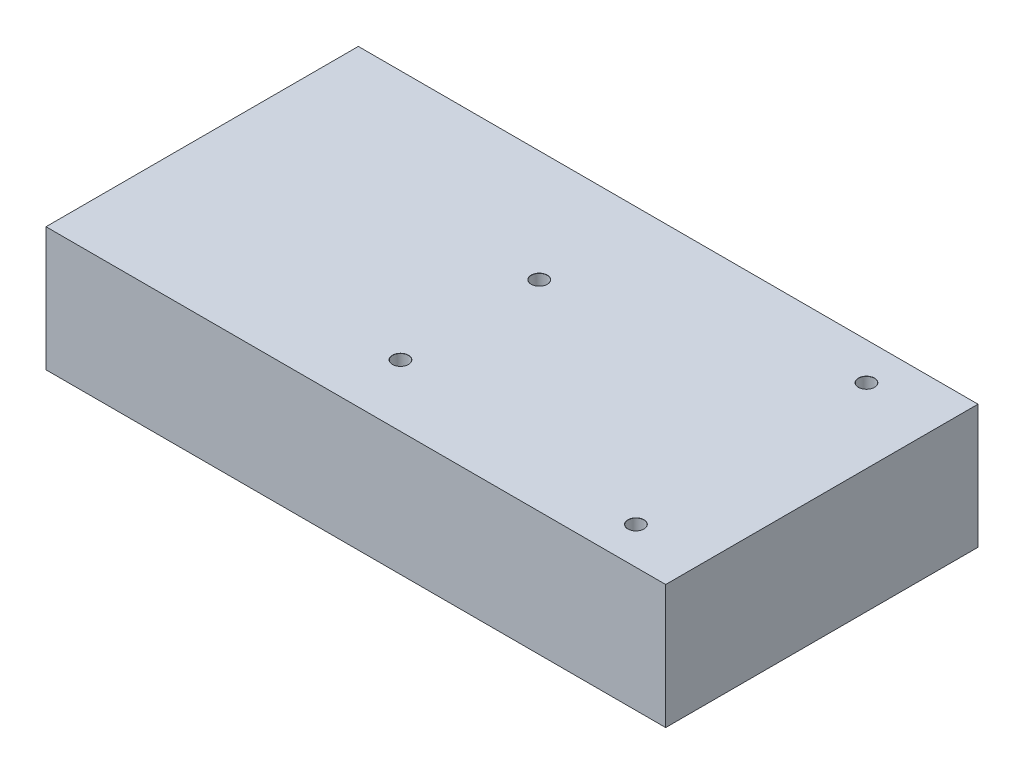
from build123d import *

# Parameters (mm, degrees)
SKETCH1_W                      = 125
SKETCH1_H                      = 63
BOSS_EXTRUDE1_DEPTH            = 25
M3_CLEARANCE_HOLE1_D           = 3.2
M3_CLEARANCE_HOLE1_CSINK_D     = 3.25
M3_CLEARANCE_HOLE1_CSINK_ANGLE = 90


with BuildPart() as part:
    # Sketch1 → Boss-Extrude1 (new body)
    with BuildSketch(Plane(origin=(0, 0, 0), x_dir=(1, 0, 0), z_dir=(0, 1, 0))):
        Rectangle(SKETCH1_W, SKETCH1_H)
    extrude(amount=BOSS_EXTRUDE1_DEPTH)

    # M3 Clearance Hole1 (through all)
    with Locations(Plane(origin=(0, 25, 0), x_dir=(1, 0, 0), z_dir=(0, 1, 0))):
        with Locations((47.5, 24), (49, -24), (-3.5, 9), (-3.5, -19)):
            CounterSinkHole(M3_CLEARANCE_HOLE1_D / 2, M3_CLEARANCE_HOLE1_CSINK_D / 2, counter_sink_angle=M3_CLEARANCE_HOLE1_CSINK_ANGLE)


solid = part.part
